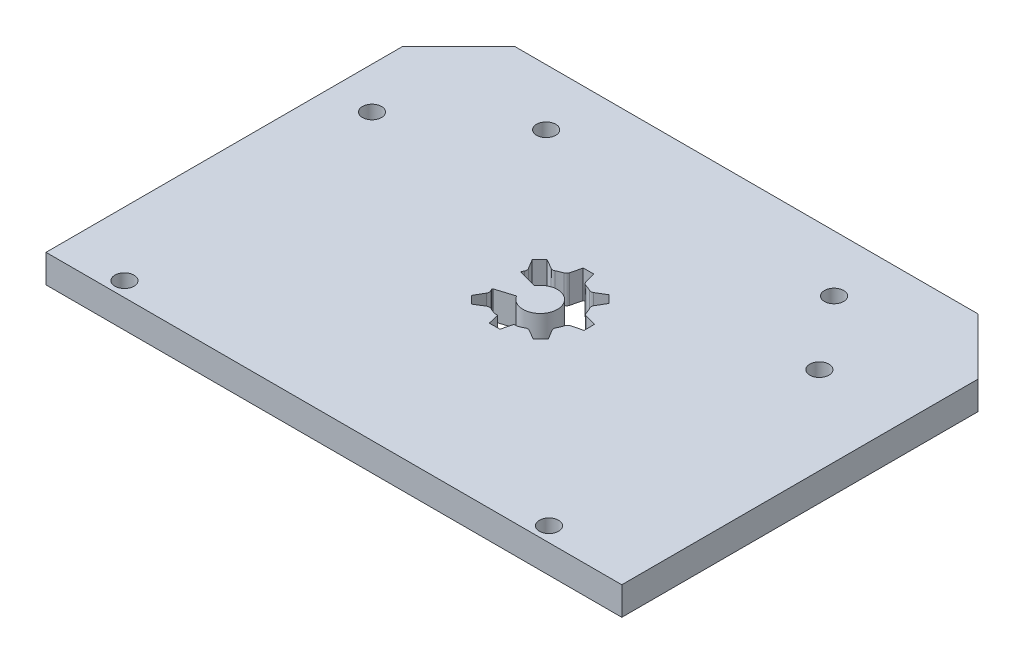
from build123d import *

# Parameters (mm, degrees)
CROQUIS1_R              = 1.7
SALIENTE_EXTRUIR1_DEPTH = 5


with BuildPart() as part:
    # Croquis1 → Saliente-Extruir1 (new body)
    with BuildSketch(Plane(origin=(0, 0, 0), x_dir=(1, 0, 0), z_dir=(0, 1, 0))):
        Polygon((0, 53.1), (0, 63.1), (10, 73.1), (92, 73.1), (102, 63.1), (102, 53.1), (102, 0), (0, 0), align=None)
        with Locations((7.35, 50.4)):
            Circle(CROQUIS1_R, mode=Mode.SUBTRACT)
        with Locations((11.3, 2.6)):
            Circle(CROQUIS1_R, mode=Mode.SUBTRACT)
        with Locations((86.5, 50.5)):
            Circle(CROQUIS1_R, mode=Mode.SUBTRACT)
        with Locations((86.5, 2.6)):
            Circle(CROQUIS1_R, mode=Mode.SUBTRACT)
        with Locations((25.5, 63.1)):
            Circle(CROQUIS1_R, mode=Mode.SUBTRACT)
        with Locations((76.5, 63.1)):
            Circle(CROQUIS1_R, mode=Mode.SUBTRACT)
        with BuildLine():
            Line((44.188139939, 41.934668839), (45.501537669, 43.270342848))
            Line((45.501537669, 43.270342848), (47.224863288, 42.26739732))
            ThreePointArc((47.224863288, 42.26739732), (47.575067996, 42.169782903), (47.928320792, 42.255715279))
            ThreePointArc((47.928320792, 42.255715279), (48.469957789, 42.515675688), (49.033343063, 42.724355067))
            ThreePointArc((49.033343063, 42.724355067), (49.340671144, 42.918574947), (49.513928995, 43.23818976))
            Line((49.513928995, 43.23818976), (49.990823409, 45.174248292))
            Line((49.990823409, 45.174248292), (51.864, 45.19))
            Line((51.864, 45.19), (52.373385647, 43.262235184))
            ThreePointArc((52.373385647, 43.262235184), (52.551993955, 42.945579245), (52.862544768, 42.756555163))
            ThreePointArc((52.862544768, 42.756555163), (53.429359729, 42.557379737), (53.975291881, 42.306564794))
            ThreePointArc((53.975291881, 42.306564794), (54.329939845, 42.226585218), (54.678453448, 42.330075218))
            Line((54.678453448, 42.330075218), (56.384668839, 43.361860061))
            Line((56.384668839, 43.361860061), (57.720342848, 42.048462331))
            Line((57.720342848, 42.048462331), (56.71739732, 40.325136712))
            ThreePointArc((56.71739732, 40.325136712), (56.619782903, 39.974932004), (56.705715279, 39.621679208))
            ThreePointArc((56.705715279, 39.621679208), (56.965675688, 39.080042211), (57.174355067, 38.516656937))
            ThreePointArc((57.174355067, 38.516656937), (57.368574947, 38.209328856), (57.68818976, 38.036071005))
            Line((57.68818976, 38.036071005), (59.624248292, 37.559176591))
            Line((59.624248292, 37.559176591), (59.64, 35.686))
            Line((59.64, 35.686), (57.712235184, 35.176614353))
            ThreePointArc((57.712235184, 35.176614353), (57.395579245, 34.998006045), (57.206555163, 34.687455232))
            ThreePointArc((57.206555163, 34.687455232), (57.007379737, 34.120640271), (56.756564794, 33.574708119))
            ThreePointArc((56.756564794, 33.574708119), (56.676585218, 33.220060155), (56.780075218, 32.871546552))
            Line((56.780075218, 32.871546552), (57.811860061, 31.165331161))
            Line((57.811860061, 31.165331161), (56.498462331, 29.829657152))
            Line((56.498462331, 29.829657152), (54.775136712, 30.83260268))
            ThreePointArc((54.775136712, 30.83260268), (54.424932004, 30.930217097), (54.071679208, 30.844284721))
            ThreePointArc((54.071679208, 30.844284721), (53.530042211, 30.584324312), (52.966656937, 30.375644933))
            ThreePointArc((52.966656937, 30.375644933), (52.724095072, 30.403806003), (52.486071005, 30.349273006))
            Line((52.486071005, 30.349273006), (52.009176591, 28.413214474))
            Line((52.009176591, 28.413214474), (50.136, 28.397462767))
            Line((50.136, 28.397462767), (49.626614353, 30.325227583))
            ThreePointArc((49.626614353, 30.325227583), (49.383630447, 30.377181799), (49.137455232, 30.343444837))
            ThreePointArc((49.137455232, 30.343444837), (48.570640271, 30.542620263), (48.024708119, 30.793435206))
            ThreePointArc((48.024708119, 30.793435206), (47.670060155, 30.873414782), (47.321546552, 30.769924782))
            Line((47.321546552, 30.769924782), (45.615331161, 29.738139939))
            Line((45.615331161, 29.738139939), (44.279657152, 31.051537669))
            Line((44.279657152, 31.051537669), (45.28260268, 32.774863288))
            ThreePointArc((45.28260268, 32.774863288), (45.380217097, 33.125067996), (45.294284721, 33.478320792))
            ThreePointArc((45.294284721, 33.478320792), (45.208247472, 33.643799276), (45.127008205, 33.811685303))
            ThreePointArc((45.127008205, 33.811685303), (45.125953752, 33.923547873), (45.209575503, 33.997856347))
            Line((45.209575503, 33.997856347), (48.384042323, 34.978554615))
            ThreePointArc((48.384042323, 34.978554615), (54.05159058, 36.528318352), (48.406635637, 38.158457784))
            Line((48.406635637, 38.158457784), (45.170602247, 39.00232588))
            ThreePointArc((45.170602247, 39.00232588), (45.082937198, 39.074508031), (45.08129489, 39.188054174))
            ThreePointArc((45.08129489, 39.188054174), (45.159930296, 39.35784363), (45.243435206, 39.525291881))
            ThreePointArc((45.243435206, 39.525291881), (45.323414782, 39.879939845), (45.219924782, 40.228453448))
            Line((45.219924782, 40.228453448), (44.188139939, 41.934668839))
        make_face(mode=Mode.SUBTRACT)
    extrude(amount=SALIENTE_EXTRUIR1_DEPTH)


solid = part.part
